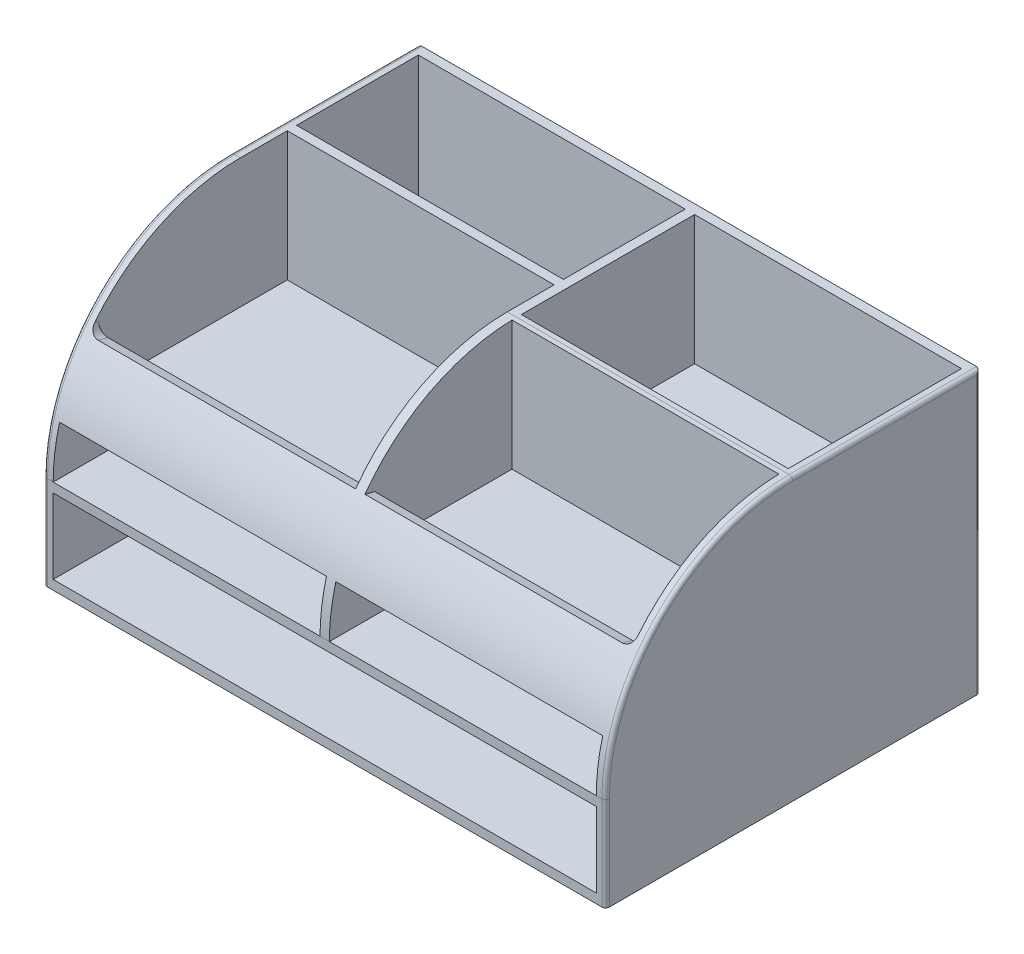
from build123d import *

# Parameters (mm, degrees)
BOSS_EXTRUDE1_DEPTH = 300
SKETCH2_W           = 142.5
SKETCH2_H           = 65
SKETCH2_H_2         = 92.5
SKETCH2_H_3         = 22.5
SKETCH2_H_4         = 2.5
CUT_EXTRUDE1_DEPTH  = 69
SKETCH3_W           = 142.5
SKETCH3_H           = 26
SKETCH3_W_2         = 290
SKETCH3_H_2         = 40
CUT_EXTRUDE2_DEPTH  = 195
BOSS_EXTRUDE2_DEPTH = 290
FILLET1_R           = 2
FILLET2_R           = 5


with BuildPart() as part:
    # Sketch1 → Boss-Extrude1 (new body)
    with BuildSketch(Plane(origin=(0, 0, 0), x_dir=(0, 0, -1), z_dir=(1, 0, 0))):
        with BuildLine():
            Line((-96.96969697, -62.878787879), (103.03030303, -62.878787879))
            Line((103.03030303, -62.878787879), (103.03030303, 87.121212121))
            Line((103.03030303, 87.121212121), (3.03030303, 87.121212121))
            ThreePointArc((3.03030303, 87.121212121), (-67.680375088, 57.83189024), (-96.96969697, -12.878787879))
            Line((-96.96969697, -12.878787879), (-96.96969697, -62.878787879))
        make_face()
    extrude(amount=-BOSS_EXTRUDE1_DEPTH)

    # Sketch2 → Cut-Extrude1 (cut)
    with BuildSketch(Plane(origin=(0, 87.121212121, 0), x_dir=(1, 0, 0), z_dir=(0, 1, 0))):
        with Locations((-223.75, 65.53030303)):
            Rectangle(SKETCH2_W, SKETCH2_H)
        with Locations((-76.25, 51.78030303)):
            Rectangle(SKETCH2_W, SKETCH2_H_2)
        with Locations((-76.25, -45.71969697)):
            Rectangle(SKETCH2_W, SKETCH2_H_2)
        with Locations((-223.75, -45.71969697)):
            Rectangle(SKETCH2_W, SKETCH2_H_2)
        with Locations((-223.75, 16.78030303)):
            Rectangle(SKETCH2_W, SKETCH2_H_3)
        with Locations((-223.75, 4.28030303)):
            Rectangle(SKETCH2_W, SKETCH2_H_4)
        with Locations((-223.75, 1.78030303)):
            Rectangle(SKETCH2_W, SKETCH2_H_4)
    extrude(amount=-CUT_EXTRUDE1_DEPTH, mode=Mode.SUBTRACT)

    # Sketch3 → Cut-Extrude2 (cut)
    with BuildSketch(Plane.XY.offset(96.96969697)):
        with Locations((-76.25, 0.121212121)):
            Rectangle(SKETCH3_W, SKETCH3_H)
        with Locations((-223.75, 0.121212121)):
            Rectangle(SKETCH3_W, SKETCH3_H)
        with Locations((-150, -37.878787879)):
            Rectangle(SKETCH3_W_2, SKETCH3_H_2)
    extrude(amount=-CUT_EXTRUDE2_DEPTH, mode=Mode.SUBTRACT)

    # Sketch4 → Boss-Extrude2 (add)
    with BuildSketch(Plane(origin=(-295, 0, 0), x_dir=(0, 0, -1), z_dir=(1, 0, 0))):
        with BuildLine():
            Line((-72.769752814, 18.121212121), (-72.769752814, 44.386834741))
            ThreePointArc((-72.769752814, 44.386834741), (-80.804635484, 31.805695829), (-86.769474252, 18.121212121))
            Line((-86.769474252, 18.121212121), (-72.769752814, 18.121212121))
        make_face()
        with BuildLine():
            ThreePointArc((-86.769474252, 18.121212121), (-80.804635484, 31.805695829), (-72.769752814, 44.386834741))
            Line((-72.769752814, 44.386834741), (-77.983342338, 45.745347629))
            ThreePointArc((-77.983342338, 45.745347629), (-86.036408668, 32.586813044), (-91.96969697, 18.346202113))
            Line((-91.96969697, 18.346202113), (-91.96969697, 18.121212121))
            Line((-91.96969697, 18.121212121), (-86.769474252, 18.121212121))
        make_face()
    extrude(amount=BOSS_EXTRUDE2_DEPTH)

    # Fillet1
    fillet1_edges = [part.edges().sort_by_distance(p)[0] for p in [
        (-300, 12.121212121, -103.03030303),
        (-300, 87.121212121, -53.03030303),
        (-300, 57.83189024, 67.680375088),
        (-300, -37.878787879, 96.96969697),
        (0, 57.83189024, 67.680375088),
        (0, 87.121212121, -53.03030303),
        (0, 12.121212121, -103.03030303),
        (0, -37.878787879, 96.96969697),
    ]]
    fillet(fillet1_edges, radius=FILLET1_R)

    # Fillet2
    fillet2_edges = [part.edges().sort_by_distance(p)[0] for p in [
        (-5, 45.066091185, 75.376547576),
        (-295, 45.066091185, 75.376547576),
    ]]
    fillet(fillet2_edges, radius=FILLET2_R)


solid = part.part
